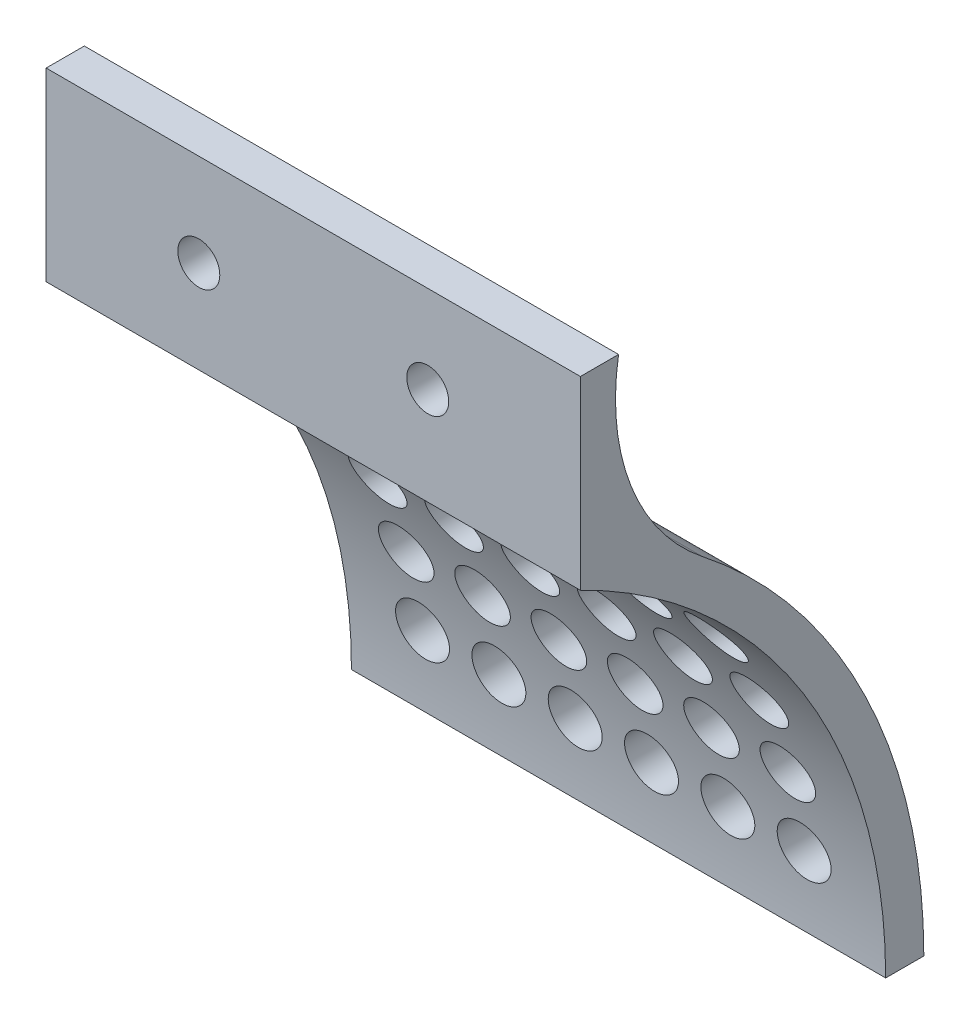
from build123d import *

# Parameters (mm, degrees)
SALIENTE_EXTRUIR1_DEPTH = 70
CROQUIS3_R              = 3.5
CORTAR_EXTRUIR3_DEPTH   = 65
CROQUIS2_R              = 2.750000002
CROQUIS2_R_2            = 2.75
CORTAR_EXTRUIR4_DEPTH   = 65


with BuildPart() as part:
    # Croquis1 → Saliente-Extruir1 (new body)
    with BuildSketch(Plane(origin=(0, 0, 0), x_dir=(0, 0, -1), z_dir=(1, 0, 0))):
        with BuildLine():
            Line((-25.193840863, 53.195024044), (-20.193840863, 53.195024044))
            ThreePointArc((-20.193840863, 53.195024044), (-18.573108699, 37.469004774), (-9.183016609, 24.750489713))
            ThreePointArc((-9.183016609, 24.750489713), (12.176943033, -1.828536951), (19.806159137, -35.062369049))
            Line((19.806159137, -35.062369049), (14.806159137, -35.062369049))
            ThreePointArc((14.806159137, -35.062369049), (3.983638383, 2.673555479), (-25.193840863, 28.937630951))
            Line((-25.193840863, 28.937630951), (-25.193840863, 53.195024044))
        make_face()
    extrude(amount=SALIENTE_EXTRUIR1_DEPTH)

    # Croquis3 → Cortar-Extruir3 (cut)
    with BuildSketch(Plane.XY.offset(-19.806159137)):
        with Locations((60, 14.750489713)):
            Circle(CROQUIS3_R)
        with Locations((50, 14.750489713)):
            Circle(CROQUIS3_R)
        with Locations((40, 14.750489713)):
            Circle(CROQUIS3_R)
        with Locations((30, 14.750489713)):
            Circle(CROQUIS3_R)
        with Locations((20, 14.750489713)):
            Circle(CROQUIS3_R)
        with Locations((10, 14.750489713)):
            Circle(CROQUIS3_R)
        with Locations((50, 4.750489713)):
            Circle(CROQUIS3_R)
        with Locations((40, 4.750489713)):
            Circle(CROQUIS3_R)
        with Locations((30, 4.750489713)):
            Circle(CROQUIS3_R)
        with Locations((20, 4.750489713)):
            Circle(CROQUIS3_R)
        with Locations((50, -5.249510287)):
            Circle(CROQUIS3_R)
        with Locations((40, -5.249510287)):
            Circle(CROQUIS3_R)
        with Locations((60, 4.750489713)):
            Circle(CROQUIS3_R)
        with Locations((20, -5.249510287)):
            Circle(CROQUIS3_R)
        with Locations((30, -5.249510287)):
            Circle(CROQUIS3_R)
        with Locations((60, -5.249510287)):
            Circle(CROQUIS3_R)
        with Locations((20, -15.249510287)):
            Circle(CROQUIS3_R)
        with Locations((30, -15.249510287)):
            Circle(CROQUIS3_R)
        with Locations((40, -15.249510287)):
            Circle(CROQUIS3_R)
        with Locations((50, -15.249510287)):
            Circle(CROQUIS3_R)
        with Locations((60, -15.249510287)):
            Circle(CROQUIS3_R)
        with Locations((20, -25.249510287)):
            Circle(CROQUIS3_R)
        with Locations((30, -25.249510287)):
            Circle(CROQUIS3_R)
        with Locations((40, -25.249510287)):
            Circle(CROQUIS3_R)
        with Locations((50, -25.249510287)):
            Circle(CROQUIS3_R)
        with Locations((60, -25.249510287)):
            Circle(CROQUIS3_R)
        with Locations((10, 4.750489713)):
            Circle(CROQUIS3_R)
        with Locations((10, -5.249510287)):
            Circle(CROQUIS3_R)
        with Locations((10, -15.249510287)):
            Circle(CROQUIS3_R)
        with Locations((10, -25.249510287)):
            Circle(CROQUIS3_R)
    extrude(amount=CORTAR_EXTRUIR3_DEPTH, mode=Mode.SUBTRACT)

    # Croquis2 → Cortar-Extruir4 (cut)
    with BuildSketch(Plane.XY.offset(25.193840863)):
        with Locations((20, 41.066327497)):
            Circle(CROQUIS2_R)
        with Locations((50, 41.717136777)):
            Circle(CROQUIS2_R_2)
    extrude(amount=-CORTAR_EXTRUIR4_DEPTH, mode=Mode.SUBTRACT)


solid = part.part
